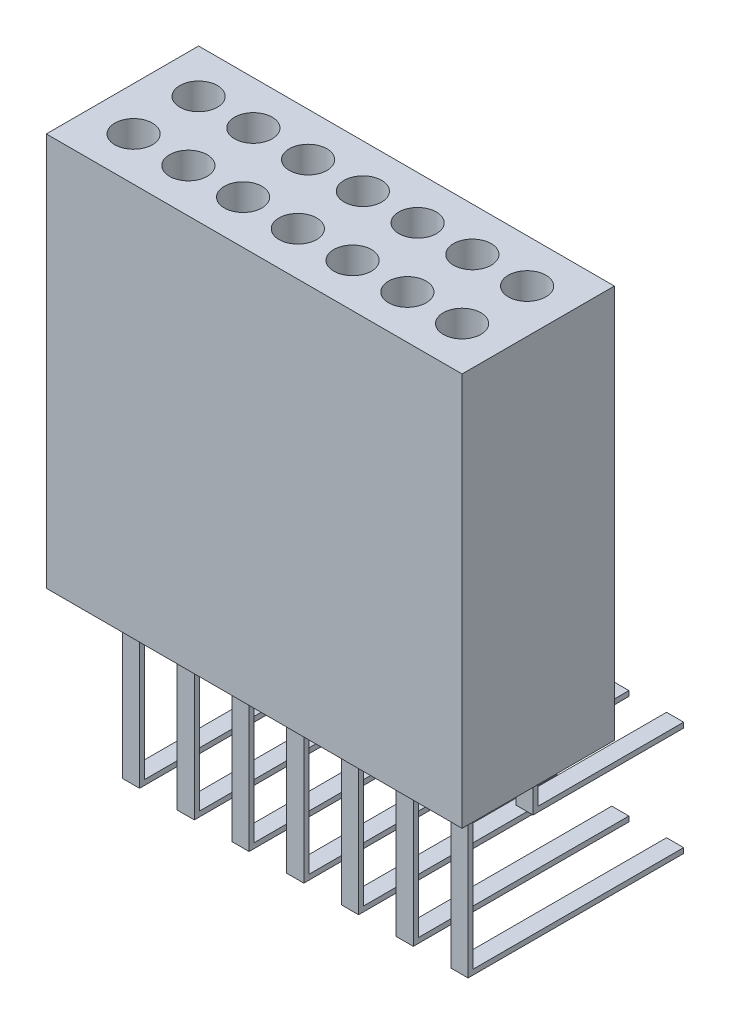
from build123d import *

# Parameters (mm, degrees)
SKETCH2_W           = 4.86
SKETCH2_H           = 1.78
BOSS_EXTRUDE1_DEPTH = 4.6
SKETCH3_R           = 0.22
CUT_EXTRUDE1_DEPTH  = 4.5
SKETCH4_W           = 0.2
SKETCH4_H           = 0.06
BOSS_EXTRUDE2_DEPTH = 1.96
SKETCH6_W           = 0.2
SKETCH6_H           = 0.06
BOSS_EXTRUDE3_DEPTH = 0.69
SKETCH7_W           = 0.2
SKETCH7_H           = 0.06
BOSS_EXTRUDE4_DEPTH = 1.7
SKETCH8_W           = 0.2
SKETCH8_H           = 0.06
BOSS_EXTRUDE5_DEPTH = 2.46


with BuildPart() as part:
    # Sketch2 → Boss-Extrude1 (new body)
    with BuildSketch(Plane(origin=(0, 0, 0), x_dir=(1, 0, 0), z_dir=(0, 1, 0))):
        with Locations((2.43, 0.89)):
            Rectangle(SKETCH2_W, SKETCH2_H)
    extrude(amount=BOSS_EXTRUDE1_DEPTH)

    # Sketch3 → Cut-Extrude1 (cut)
    with BuildSketch(Plane(origin=(0, 4.6, 0), x_dir=(1, 0, 0), z_dir=(0, 1, 0))):
        with Locations((0.51, 1.27)):
            Circle(SKETCH3_R)
        with Locations((1.15, 1.27)):
            Circle(SKETCH3_R)
        with Locations((1.79, 1.27)):
            Circle(SKETCH3_R)
        with Locations((2.43, 1.27)):
            Circle(SKETCH3_R)
        with Locations((3.07, 1.27)):
            Circle(SKETCH3_R)
        with Locations((3.71, 1.27)):
            Circle(SKETCH3_R)
        with Locations((4.35, 1.27)):
            Circle(SKETCH3_R)
        with Locations((1.15, 0.51)):
            Circle(SKETCH3_R)
        with Locations((1.79, 0.51)):
            Circle(SKETCH3_R)
        with Locations((2.43, 0.51)):
            Circle(SKETCH3_R)
        with Locations((3.07, 0.51)):
            Circle(SKETCH3_R)
        with Locations((3.71, 0.51)):
            Circle(SKETCH3_R)
        with Locations((4.35, 0.51)):
            Circle(SKETCH3_R)
        with Locations((0.51, 0.51)):
            Circle(SKETCH3_R)
    extrude(amount=-CUT_EXTRUDE1_DEPTH, mode=Mode.SUBTRACT)

    # Sketch4 → Boss-Extrude2 (add)
    with BuildSketch(Plane.XZ):
        with Locations((0.51, -0.51)):
            Rectangle(SKETCH4_W, SKETCH4_H)
        with Locations((1.15, -0.51)):
            Rectangle(SKETCH4_W, SKETCH4_H)
        with Locations((1.79, -0.51)):
            Rectangle(SKETCH4_W, SKETCH4_H)
        with Locations((2.43, -0.51)):
            Rectangle(SKETCH4_W, SKETCH4_H)
        with Locations((3.07, -0.51)):
            Rectangle(SKETCH4_W, SKETCH4_H)
        with Locations((3.71, -0.51)):
            Rectangle(SKETCH4_W, SKETCH4_H)
        with Locations((4.35, -0.51)):
            Rectangle(SKETCH4_W, SKETCH4_H)
    extrude(amount=BOSS_EXTRUDE2_DEPTH)

    # Sketch6 → Boss-Extrude3 (add)
    with BuildSketch(Plane.XZ):
        with Locations((0.51, -1.27)):
            Rectangle(SKETCH6_W, SKETCH6_H)
        with Locations((1.15, -1.27)):
            Rectangle(SKETCH6_W, SKETCH6_H)
        with Locations((1.79, -1.27)):
            Rectangle(SKETCH6_W, SKETCH6_H)
        with Locations((2.43, -1.27)):
            Rectangle(SKETCH6_W, SKETCH6_H)
        with Locations((3.07, -1.27)):
            Rectangle(SKETCH6_W, SKETCH6_H)
        with Locations((3.71, -1.27)):
            Rectangle(SKETCH6_W, SKETCH6_H)
        with Locations((4.35, -1.27)):
            Rectangle(SKETCH6_W, SKETCH6_H)
    extrude(amount=BOSS_EXTRUDE3_DEPTH)

    # Sketch7 → Boss-Extrude4 (add)
    with BuildSketch(Plane(origin=(0, 0, -1.3), x_dir=(-1, 0, 0), z_dir=(0, 0, -1))):
        with Locations((-4.35, -0.66)):
            Rectangle(SKETCH7_W, SKETCH7_H)
        with Locations((-3.71, -0.66)):
            Rectangle(SKETCH7_W, SKETCH7_H)
        with Locations((-3.07, -0.66)):
            Rectangle(SKETCH7_W, SKETCH7_H)
        with Locations((-2.43, -0.66)):
            Rectangle(SKETCH7_W, SKETCH7_H)
        with Locations((-1.79, -0.66)):
            Rectangle(SKETCH7_W, SKETCH7_H)
        with Locations((-1.15, -0.66)):
            Rectangle(SKETCH7_W, SKETCH7_H)
        with Locations((-0.51, -0.66)):
            Rectangle(SKETCH7_W, SKETCH7_H)
    extrude(amount=BOSS_EXTRUDE4_DEPTH)

    # Sketch8 → Boss-Extrude5 (add)
    with BuildSketch(Plane(origin=(0, 0, -0.54), x_dir=(-1, 0, 0), z_dir=(0, 0, -1))):
        with Locations((-4.35, -1.93)):
            Rectangle(SKETCH8_W, SKETCH8_H)
        with Locations((-3.71, -1.93)):
            Rectangle(SKETCH8_W, SKETCH8_H)
        with Locations((-3.07, -1.93)):
            Rectangle(SKETCH8_W, SKETCH8_H)
        with Locations((-2.43, -1.93)):
            Rectangle(SKETCH8_W, SKETCH8_H)
        with Locations((-1.79, -1.93)):
            Rectangle(SKETCH8_W, SKETCH8_H)
        with Locations((-1.15, -1.93)):
            Rectangle(SKETCH8_W, SKETCH8_H)
        with Locations((-0.51, -1.93)):
            Rectangle(SKETCH8_W, SKETCH8_H)
    extrude(amount=BOSS_EXTRUDE5_DEPTH)


solid = part.part
